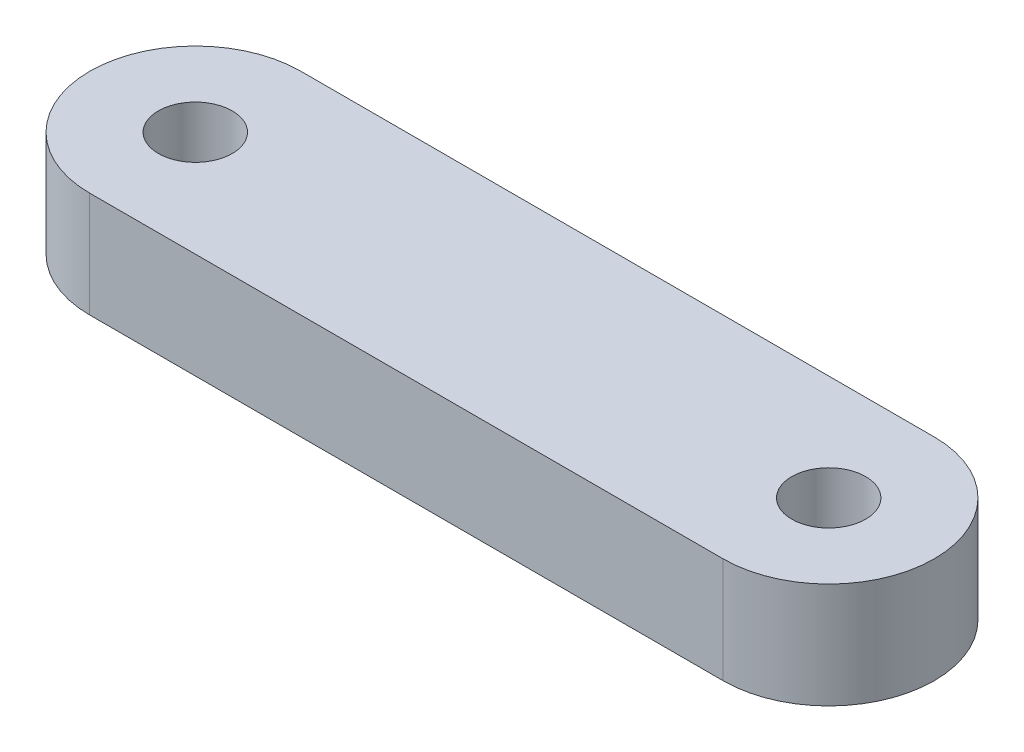
from build123d import *

# Parameters (mm, degrees)
SKETCH1_R           = 1.75
BOSS_EXTRUDE1_DEPTH = 5


with BuildPart() as part:
    # Sketch1 → Boss-Extrude1 (new body)
    with BuildSketch(Plane(origin=(0, 0, 0), x_dir=(1, 0, 0), z_dir=(0, 1, 0))):
        with BuildLine():
            Line((0, 0), (30, 0))
            ThreePointArc((30, 0), (35, 5), (30, 10))
            Line((30, 10), (0, 10))
            ThreePointArc((0, 10), (-5, 5), (0, 0))
        make_face()
        with Locations((0, 5)):
            Circle(SKETCH1_R, mode=Mode.SUBTRACT)
        with Locations((30, 5)):
            Circle(SKETCH1_R, mode=Mode.SUBTRACT)
    extrude(amount=BOSS_EXTRUDE1_DEPTH)


solid = part.part
